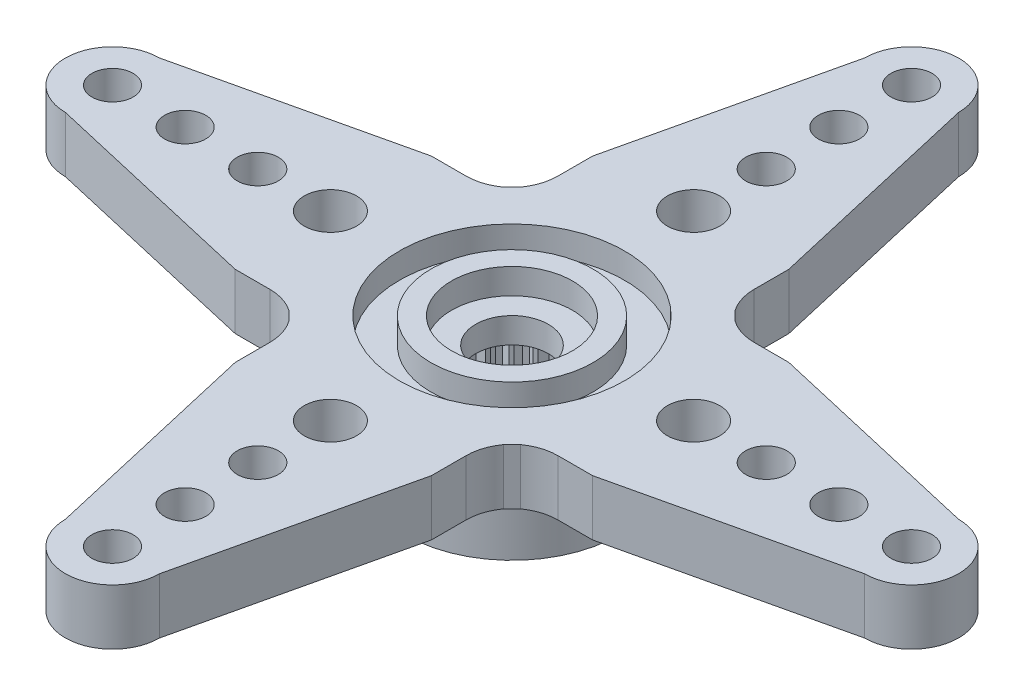
from build123d import *

# Parameters (mm, degrees)
IZIM1_R                     = 4.45
Y_KSEKLIK_EKSTR_ZYON1_DEPTH = 5.6
IZIM2_R                     = 0.85
IZIM2_R_2                   = 1.08184978
Y_KSEKLIK_EKSTR_ZYON2_DEPTH = 2.3
DAIRESEL_KAPLAMA1_COUNT     = 4
IZIM3_R                     = 2.5
KES_EKSTR_ZYON1_DEPTH       = 1.05
IZIM4_R                     = 4.65
IZIM4_R_2                   = 3.35
KES_EKSTR_ZYON2_DEPTH       = 1.05
IZIM5_R                     = 1.5
KES_EKSTR_ZYON3_DEPTH       = 7.05
IZIM6_R                     = 2.68
KES_EKSTR_ZYON4_DEPTH       = 3.5
KES_EKSTR_ZYON5_DEPTH       = 3.5
DAIRESEL_KAPLAMA2_COUNT     = 24


with BuildPart() as part:
    # Çizim1 → Yükseklik-Ekstrüzyon1 (new body)
    with BuildSketch(Plane(origin=(0, 0, 0), x_dir=(1, 0, 0), z_dir=(0, 1, 0))):
        with Locations(Location((0, 0, 0), (0, 0, 270))):
            Circle(IZIM1_R)
    extrude(amount=Y_KSEKLIK_EKSTR_ZYON1_DEPTH)

    # Çizim2 → Yükseklik-Ekstrüzyon2 (add)
    with BuildSketch(Plane(origin=(0, 5.6, 0), x_dir=(1, 0, 0), z_dir=(0, 1, 0))):
        with BuildLine():
            Line((0, 4.69), (0, -4.69))
            Line((0, -4.69), (-4.520042194, -4.69))
            Line((-4.520042194, -4.69), (-4.783580891, -4.426461303))
            ThreePointArc((-4.783580891, -4.426461303), (-5.337293558, -4.147310093), (-5.949896194, -4.051179314))
            Line((-5.949896194, -4.051179314), (-7.379896194, -4.051179314))
            Line((-7.379896194, -4.051179314), (-16.5, -1.945637445))
            ThreePointArc((-16.5, -1.945637445), (-18.445637445, 0), (-16.5, 1.945637445))
            Line((-16.5, 1.945637445), (-7.379896194, 4.051179314))
            Line((-7.379896194, 4.051179314), (-5.949896194, 4.051179314))
            ThreePointArc((-5.949896194, 4.051179314), (-5.337293558, 4.147310093), (-4.783580891, 4.426461303))
            Line((-4.783580891, 4.426461303), (-4.520042194, 4.69))
            Line((-4.520042194, 4.69), (0, 4.69))
        make_face()
        with Locations(Location((-16.5, 0, 0), (0, 0, 270))):
            Circle(IZIM2_R, mode=Mode.SUBTRACT)
        with Locations(Location((-13.5, 0, 0), (0, 0, 270))):
            Circle(IZIM2_R, mode=Mode.SUBTRACT)
        with Locations(Location((-10.5, 0, 0), (0, 0, 270))):
            Circle(IZIM2_R, mode=Mode.SUBTRACT)
        with Locations(Location((-7.5, 0, 0), (0, 0, 270))):
            Circle(IZIM2_R_2, mode=Mode.SUBTRACT)
    y_kseklik_ekstr_zyon2 = extrude(amount=-Y_KSEKLIK_EKSTR_ZYON2_DEPTH)

    # Dairesel Kaplama1: Yükseklik-Ekstrüzyon2 ×4 about axis
    dairesel_kaplama1_axis = Axis((0, 0, 0), (0, 1, 0))
    for i in range(1, DAIRESEL_KAPLAMA1_COUNT):
        add(y_kseklik_ekstr_zyon2.rotate(dairesel_kaplama1_axis, i * 360 / DAIRESEL_KAPLAMA1_COUNT))

    # Çizim3 → Kes-Ekstrüzyon1 (cut)
    with BuildSketch(Plane(origin=(0, 5.6, 0), x_dir=(1, 0, 0), z_dir=(0, 1, 0))):
        with Locations(Location((0, 0, 0), (0, 0, 270))):
            Circle(IZIM3_R)
    extrude(amount=-KES_EKSTR_ZYON1_DEPTH, mode=Mode.SUBTRACT)

    # Çizim4 → Kes-Ekstrüzyon2 (cut)
    with BuildSketch(Plane(origin=(0, 4.55, 0), x_dir=(1, 0, 0), z_dir=(0, 1, 0))):
        with Locations(Location((0, 0, 0), (0, 0, 270))):
            Circle(IZIM4_R)
        with Locations(Location((0, 0, 0), (0, 0, 270))):
            Circle(IZIM4_R_2, mode=Mode.SUBTRACT)
    extrude(amount=KES_EKSTR_ZYON2_DEPTH, mode=Mode.SUBTRACT)

    # Çizim5 → Kes-Ekstrüzyon3 (cut)
    with BuildSketch(Plane(origin=(0, 4.55, 0), x_dir=(1, 0, 0), z_dir=(0, 1, 0))):
        with Locations(Location((0, 0, 0), (0, 0, 270))):
            Circle(IZIM5_R)
    extrude(amount=-KES_EKSTR_ZYON3_DEPTH, mode=Mode.SUBTRACT)

    # Çizim6 → Kes-Ekstrüzyon4 (cut)
    with BuildSketch(Plane.XZ):
        with Locations(Location((0, 0, 0), (0, 0, 270))):
            Circle(IZIM6_R)
    extrude(amount=-KES_EKSTR_ZYON4_DEPTH, mode=Mode.SUBTRACT)

    # Çizim7 → Kes-Ekstrüzyon5 (cut)
    with BuildSketch(Plane.XZ.offset(-3.5)):
        with BuildLine():
            Line((-2.357417444, 1.923535533), (-2.484485613, 1.756341991))
            Line((-2.484485613, 1.756341991), (-2.274980692, 1.416637869))
            ThreePointArc((-2.274980692, 1.416637869), (-2.117608163, 1.642600277), (-1.937879889, 1.851221633))
            Line((-1.937879889, 1.851221633), (-2.357417444, 1.923535533))
        make_face()
    kes_ekstr_zyon5 = extrude(amount=KES_EKSTR_ZYON5_DEPTH, mode=Mode.SUBTRACT)

    # Dairesel Kaplama2: Kes-Ekstrüzyon5 ×24 about axis
    dairesel_kaplama2_axis = Axis((0, 0, 0), (0, 1, 0))
    for i in range(1, DAIRESEL_KAPLAMA2_COUNT):
        add(kes_ekstr_zyon5.rotate(dairesel_kaplama2_axis, i * 360 / DAIRESEL_KAPLAMA2_COUNT), mode=Mode.SUBTRACT)


solid = part.part
